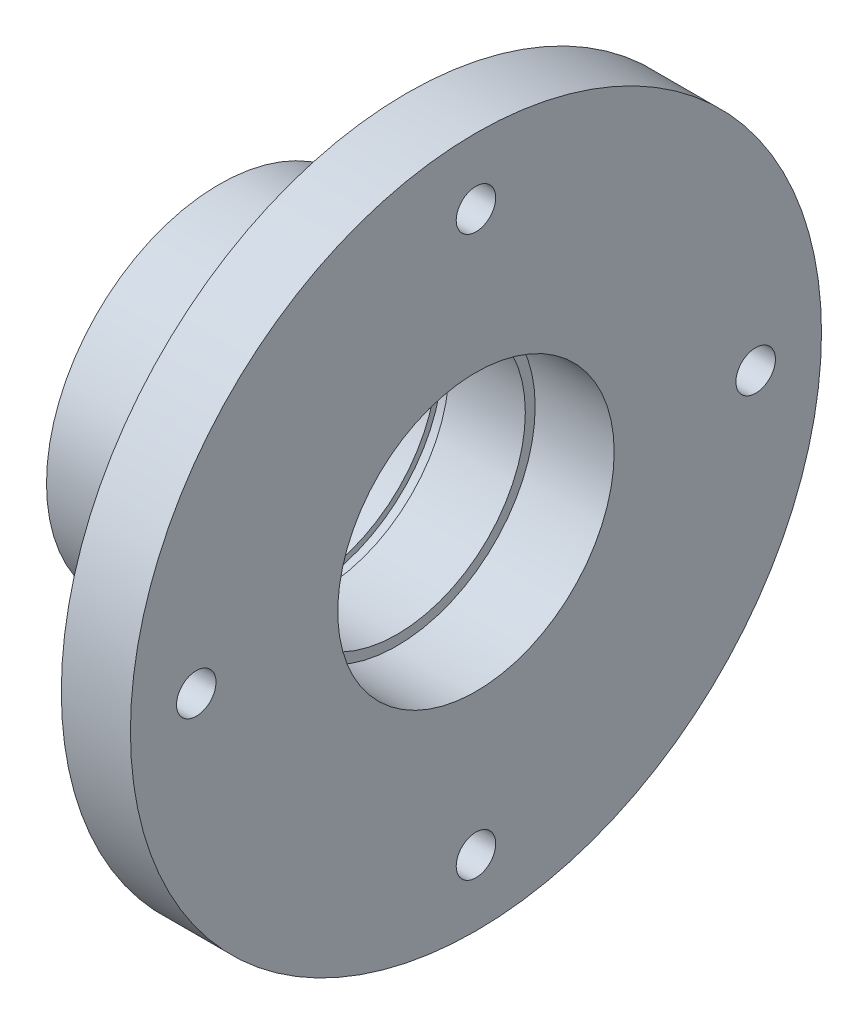
from build123d import *

# Parameters (mm, degrees)
SKETCH1_R           = 35
BOSS_EXTRUDE1_DEPTH = 26
SKETCH2_R           = 35
SKETCH2_R_2         = 17.5
CUT_EXTRUDE1_DEPTH  = 19
SKETCH3_R           = 2
CUT_EXTRUDE2_DEPTH  = 18
SKETCH4_R           = 5.5
CUT_EXTRUDE4_DEPTH  = 3
CUT_EXTRUDE5_REACH  = 28
SKETCH5_R           = 9.5
SKETCH6_R           = 13
CUT_EXTRUDE6_DEPTH  = 22
CUT_EXTRUDE7_REACH  = 54.5
SKETCH7_R           = 2.5
SKETCH8_R           = 14
CUT_EXTRUDE8_DEPTH  = 8
SKETCH9_R           = 13.6
CUT_EXTRUDE9_DEPTH  = 0.625


with BuildPart() as part:
    # Sketch1 → Boss-Extrude1 (new body)
    with BuildSketch(Plane(origin=(0, 0, 0), x_dir=(0, 0, -1), z_dir=(1, 0, 0))):
        Circle(SKETCH1_R)
    extrude(amount=-BOSS_EXTRUDE1_DEPTH)

    # Sketch2 → Cut-Extrude1 (cut)
    with BuildSketch(Plane.ZY.offset(26)):
        Circle(SKETCH2_R)
        Circle(SKETCH2_R_2, mode=Mode.SUBTRACT)
    extrude(amount=-CUT_EXTRUDE1_DEPTH, mode=Mode.SUBTRACT)

    # Sketch3 → Cut-Extrude2 (cut)
    with BuildSketch(Plane.ZY.offset(7)):
        with Locations((0, 28.33)):
            Circle(SKETCH3_R)
        with Locations((28.33, 0)):
            Circle(SKETCH3_R)
        with Locations((0, -28.33)):
            Circle(SKETCH3_R)
        with Locations((-28.33, 0)):
            Circle(SKETCH3_R)
    extrude(amount=-CUT_EXTRUDE2_DEPTH, mode=Mode.SUBTRACT)

    # Sketch4 → Cut-Extrude4 (cut)
    with BuildSketch(Plane.ZY.offset(7)):
        with Locations((0, 28.33)):
            Circle(SKETCH4_R)
        with Locations((28.33, 0)):
            Circle(SKETCH4_R)
        with Locations((0, -28.33)):
            Circle(SKETCH4_R)
        with Locations((-28.33, 0)):
            Circle(SKETCH4_R)
    extrude(amount=-CUT_EXTRUDE4_DEPTH, mode=Mode.SUBTRACT)

    # Sketch5 → Cut-Extrude5 (cut, up to next)
    with BuildSketch(Plane.ZY.offset(26), mode=Mode.PRIVATE) as cut_extrude5_sk1:
        Circle(SKETCH5_R)
    cut_extrude5_tool1 = extrude(cut_extrude5_sk1.sketch, amount=-CUT_EXTRUDE5_REACH, mode=Mode.PRIVATE) & part.part
    add(cut_extrude5_tool1.solids().sort_by_distance((-26, 0, 0))[0], mode=Mode.SUBTRACT)

    # Sketch6 → Cut-Extrude6 (cut)
    with BuildSketch(Plane(origin=(0, 0, 0), x_dir=(0, 0, -1), z_dir=(1, 0, 0))):
        Circle(SKETCH6_R)
    extrude(amount=-CUT_EXTRUDE6_DEPTH, mode=Mode.SUBTRACT)

    # Sketch7 → Cut-Extrude7 (cut, up to next)
    with BuildSketch(Plane(origin=(0, 17.5, 0), x_dir=(1, 0, 0), z_dir=(0, 1, 0)), mode=Mode.PRIVATE) as cut_extrude7_sk1:
        with Locations((-11, 0)):
            Circle(SKETCH7_R)
    cut_extrude7_tool1 = extrude(cut_extrude7_sk1.sketch, amount=-CUT_EXTRUDE7_REACH, mode=Mode.PRIVATE) & part.part
    add(cut_extrude7_tool1.solids().sort_by_distance((-11, 17.5, 0))[0], mode=Mode.SUBTRACT)

    # Sketch8 → Cut-Extrude8 (cut)
    with BuildSketch(Plane(origin=(0, 0, 0), x_dir=(0, 0, -1), z_dir=(1, 0, 0))):
        Circle(SKETCH8_R)
    extrude(amount=-CUT_EXTRUDE8_DEPTH, mode=Mode.SUBTRACT)

    # Sketch9 → Cut-Extrude9 (cut, symmetric)
    with BuildSketch(Plane(origin=(-16.35, 0, 0), x_dir=(0, 0, -1), z_dir=(1, 0, 0))):
        Circle(SKETCH9_R)
    extrude(amount=CUT_EXTRUDE9_DEPTH, both=True, mode=Mode.SUBTRACT)


solid = part.part
